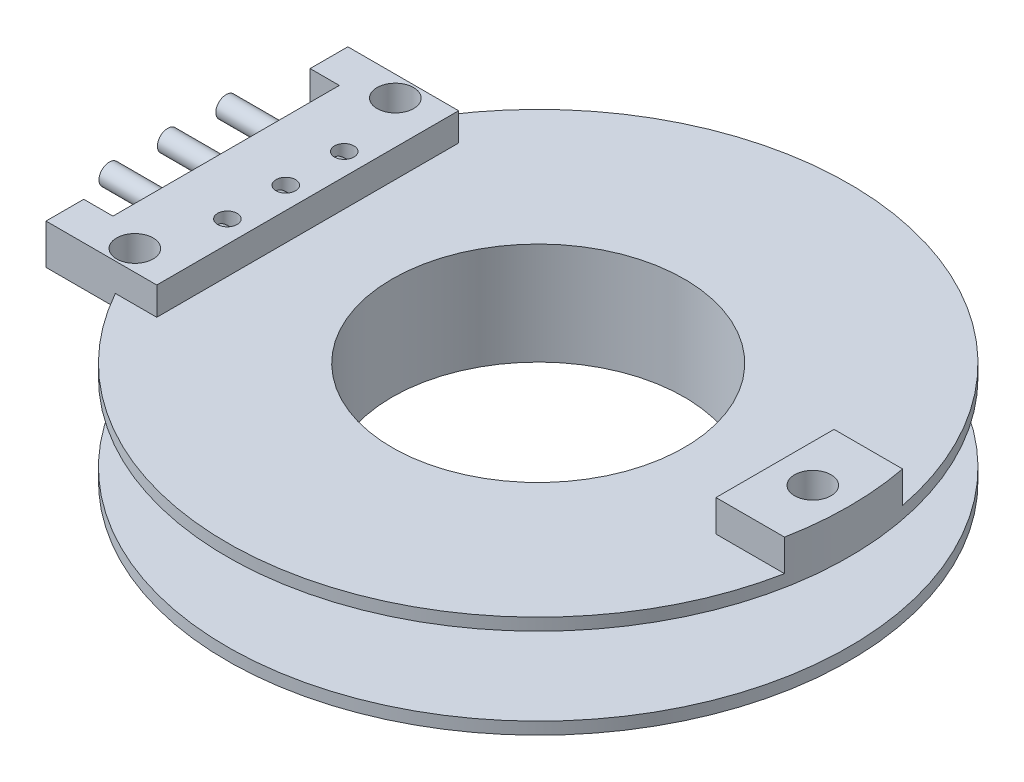
from build123d import *

# Parameters (mm, degrees)
EXTRUDE_1_DEPTH        = 1.3
EXTRUDE_2_DEPTH        = 1.15
EXTRUDE_2_DEPTH_BACK   = 0.5
SKETCH_4_R             = 0.75
CUT_EXTRUDE_1_DEPTH    = 1.65
SKETCH_5_R             = 0.4
CUT_EXTRUDE_2_DEPTH    = 1.55
SKETCH_6_R             = 0.425
EXTRUDE_3_DEPTH        = 2.4
EXTRUDE_3_DEPTH_BACK   = 3
EXTRUDE_3_2_DEPTH      = 2.4
EXTRUDE_3_2_DEPTH_BACK = 3
EXTRUDE_3_3_DEPTH      = 2.4
EXTRUDE_3_3_DEPTH_BACK = 3
SKETCH_7_R             = 0.75
CUT_EXTRUDE_3_DEPTH    = 1.8


with BuildPart() as part:
    # Эскиз1 → Повернуть1 (revolve)
    with BuildSketch(Plane.XY):
        Polygon((7, 1.6), (7, -1.6), (12.775, -1.6), (12.775, -2.1), (6, -2.1), (6, 2.1), (12.775, 2.1), (12.775, 1.6), align=None)
    revolve(axis=Axis((0, 2.1, 0), (0, -1, 0)))

    # Эскиз2 → Бобышка-Вытянуть1 (add)
    with BuildSketch(Plane(origin=(0, 2.1, 0), x_dir=(1, 0, 0), z_dir=(0, 1, 0))):
        with BuildLine():
            Line((9.727281223, 2.425), (12.542726976, 2.425))
            ThreePointArc((12.542726976, 2.425), (12.775, 0), (12.542726976, -2.425))
            Line((12.542726976, -2.425), (9.727281223, -2.425))
            Line((9.727281223, -2.425), (9.727281223, 2.425))
        make_face()
    extrude(amount=EXTRUDE_1_DEPTH)

    # Эскиз3 → Бобышка-Вытянуть2 (add, two sides)
    with BuildSketch(Plane(origin=(0, 2.1, 0), x_dir=(1, 0, 0), z_dir=(0, 1, 0))) as extrude_2_sk:
        Polygon((-14.02, 6.2), (-9.47, 6.2), (-9.47, -6.2), (-14.02, -6.2), (-14.02, -4.65), (-12.82, -4.65), (-12.82, 4.65), (-14.02, 4.65), align=None)
    extrude(amount=EXTRUDE_2_DEPTH)
    extrude(extrude_2_sk.sketch, amount=-EXTRUDE_2_DEPTH_BACK)

    # Эскиз4 → Вырез-Вытянуть1 (cut)
    with BuildSketch(Plane(origin=(0, 3.25, 0), x_dir=(1, 0, 0), z_dir=(0, 1, 0))):
        with Locations((-11.22, 5.35)):
            Circle(SKETCH_4_R)
        with Locations((-11.22, -5.35)):
            Circle(SKETCH_4_R)
    extrude(amount=-CUT_EXTRUDE_1_DEPTH, mode=Mode.SUBTRACT)

    # Эскиз5 → Вырез-Вытянуть2 (cut)
    with BuildSketch(Plane(origin=(0, 3.25, 0), x_dir=(1, 0, 0), z_dir=(0, 1, 0))):
        with Locations((-10.37, 2.4)):
            Circle(SKETCH_5_R)
        with Locations((-10.37, 0)):
            Circle(SKETCH_5_R)
        with Locations((-10.37, -2.4)):
            Circle(SKETCH_5_R)
    extrude(amount=-CUT_EXTRUDE_2_DEPTH, mode=Mode.SUBTRACT)

    # Эскиз7 → Вырез-Вытянуть3 (cut)
    with BuildSketch(Plane(origin=(0, 3.4, 0), x_dir=(1, 0, 0), z_dir=(0, 1, 0))):
        with Locations((11.28, 0)):
            Circle(SKETCH_7_R)
    extrude(amount=-CUT_EXTRUDE_3_DEPTH, mode=Mode.SUBTRACT)


with BuildPart() as body_2:
    # Эскиз6 → Бобышка-Вытянуть3 (new body, two sides)
    with BuildSketch(Plane.ZY.offset(12.82)) as extrude_3_sk:
        with Locations((0, 2.425)):
            Circle(SKETCH_6_R)
    extrude(amount=EXTRUDE_3_DEPTH)
    extrude(extrude_3_sk.sketch, amount=-EXTRUDE_3_DEPTH_BACK)


with BuildPart() as body_3:
    # Эскиз6 → Extrude 3 2 (new body, two sides)
    with BuildSketch(Plane.ZY.offset(12.82)) as extrude_3_2_sk:
        with Locations((2.4, 2.425)):
            Circle(SKETCH_6_R)
    extrude(amount=EXTRUDE_3_2_DEPTH)
    extrude(extrude_3_2_sk.sketch, amount=-EXTRUDE_3_2_DEPTH_BACK)


with BuildPart() as body_4:
    # Эскиз6 → Extrude 3 3 (new body, two sides)
    with BuildSketch(Plane.ZY.offset(12.82)) as extrude_3_3_sk:
        with Locations((-2.4, 2.425)):
            Circle(SKETCH_6_R)
    extrude(amount=EXTRUDE_3_3_DEPTH)
    extrude(extrude_3_3_sk.sketch, amount=-EXTRUDE_3_3_DEPTH_BACK)


solid = Compound([part.part, body_2.part, body_3.part, body_4.part])
